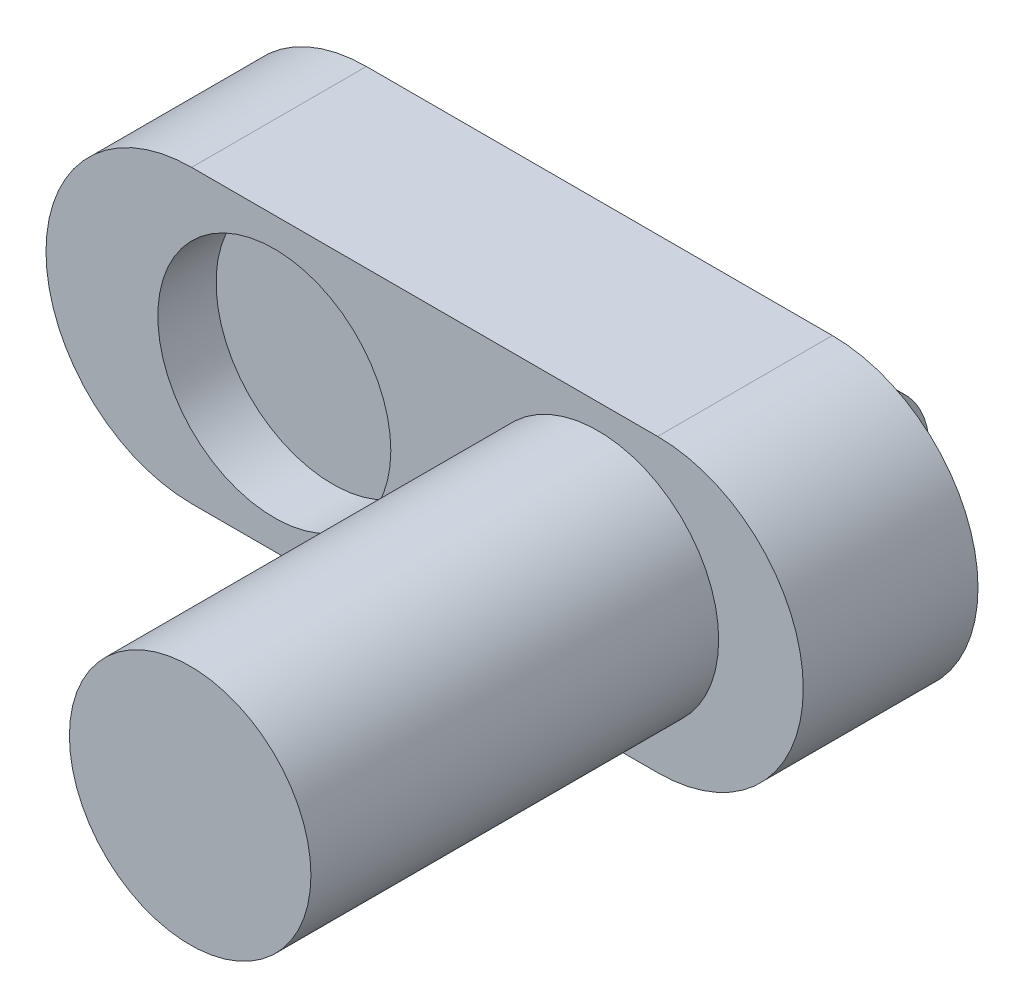
from build123d import *

# Parameters (mm, degrees)
BOSS_EXTRUDE1_DEPTH = 5
BOSS_EXTRUDE2_DEPTH = 5
BOSS_EXTRUDE3_DEPTH = 5
SKETCH5_R           = 10
SKETCH5_R_2         = 7.5
CUT_EXTRUDE1_DEPTH  = 5
SKETCH6_R           = 10.366071997
BOSS_EXTRUDE4_DEPTH = 35
SKETCH7_R           = 7.5
CUT_EXTRUDE2_DEPTH  = 5
BOSS_EXTRUDE5_DEPTH = 40
SKETCH10_R          = 2.25
CUT_EXTRUDE3_DEPTH  = 40


with BuildPart() as part:
    # Sketch1 → Boss-Extrude1 (new body)
    with BuildSketch(Plane.XY):
        with BuildLine():
            Line((-20, 12.5), (20, 12.5))
            ThreePointArc((20, 12.5), (32.5, 0), (20, -12.5))
            Line((20, -12.5), (-20, -12.5))
            ThreePointArc((-20, -12.5), (-32.5, 0), (-20, 12.5))
        make_face()
    extrude(amount=BOSS_EXTRUDE1_DEPTH)

    # Sketch2 → Boss-Extrude2 (add)
    with BuildSketch(Plane.XY.offset(5)):
        with BuildLine():
            Line((-20, 12.5), (20, 12.5))
            ThreePointArc((20, 12.5), (32.5, 0), (20, -12.5))
            Line((20, -12.5), (-20, -12.5))
            ThreePointArc((-20, -12.5), (-32.5, 0), (-20, 12.5))
        make_face()
    extrude(amount=BOSS_EXTRUDE2_DEPTH)

    # Sketch4 → Boss-Extrude3 (add)
    with BuildSketch(Plane.XY.offset(10)):
        with BuildLine():
            Line((-20, 12.5), (20, 12.5))
            ThreePointArc((20, 12.5), (32.5, 0), (20, -12.5))
            Line((20, -12.5), (-20, -12.5))
            ThreePointArc((-20, -12.5), (-32.5, 0), (-20, 12.5))
        make_face()
    extrude(amount=BOSS_EXTRUDE3_DEPTH)

    # Sketch5 → Cut-Extrude1 (cut)
    with BuildSketch(Plane.XY.offset(15)):
        with Locations((-12.902032685, 0)):
            Circle(SKETCH5_R)
        with Locations((-12.902032685, 0)):
            Circle(SKETCH5_R_2, mode=Mode.SUBTRACT)
    extrude(amount=-CUT_EXTRUDE1_DEPTH, mode=Mode.SUBTRACT)

    # Sketch6 → Boss-Extrude4 (add)
    with BuildSketch(Plane.XY.offset(15)):
        with Locations((14.874986592, 0)):
            Circle(SKETCH6_R)
    extrude(amount=BOSS_EXTRUDE4_DEPTH)

    # Sketch7 → Cut-Extrude2 (cut)
    with BuildSketch(Plane.XY.offset(15)):
        with Locations((-12.902032685, 0)):
            Circle(SKETCH7_R)
    extrude(amount=-CUT_EXTRUDE2_DEPTH, mode=Mode.SUBTRACT)

    # Sketch9 → Boss-Extrude5 (add)
    with BuildSketch(Plane(origin=(20, 0, 0), x_dir=(0, 0, -1), z_dir=(1, 0, 0))):
        with BuildLine():
            Line((0, 6.25), (0, 0))
            Line((0, 0), (0, -6.25))
            Line((0, -6.25), (4.5, -6.25))
            ThreePointArc((4.5, -6.25), (8.319298262, 0), (4.5, 6.25))
            Line((4.5, 6.25), (0, 6.25))
        make_face()
    extrude(amount=-BOSS_EXTRUDE5_DEPTH)

    # Sketch10 → Cut-Extrude3 (cut)
    with BuildSketch(Plane(origin=(20, 0, 0), x_dir=(0, 0, -1), z_dir=(1, 0, 0))):
        with Locations((4.159649131, 0)):
            Circle(SKETCH10_R)
    extrude(amount=-CUT_EXTRUDE3_DEPTH, mode=Mode.SUBTRACT)


solid = part.part
